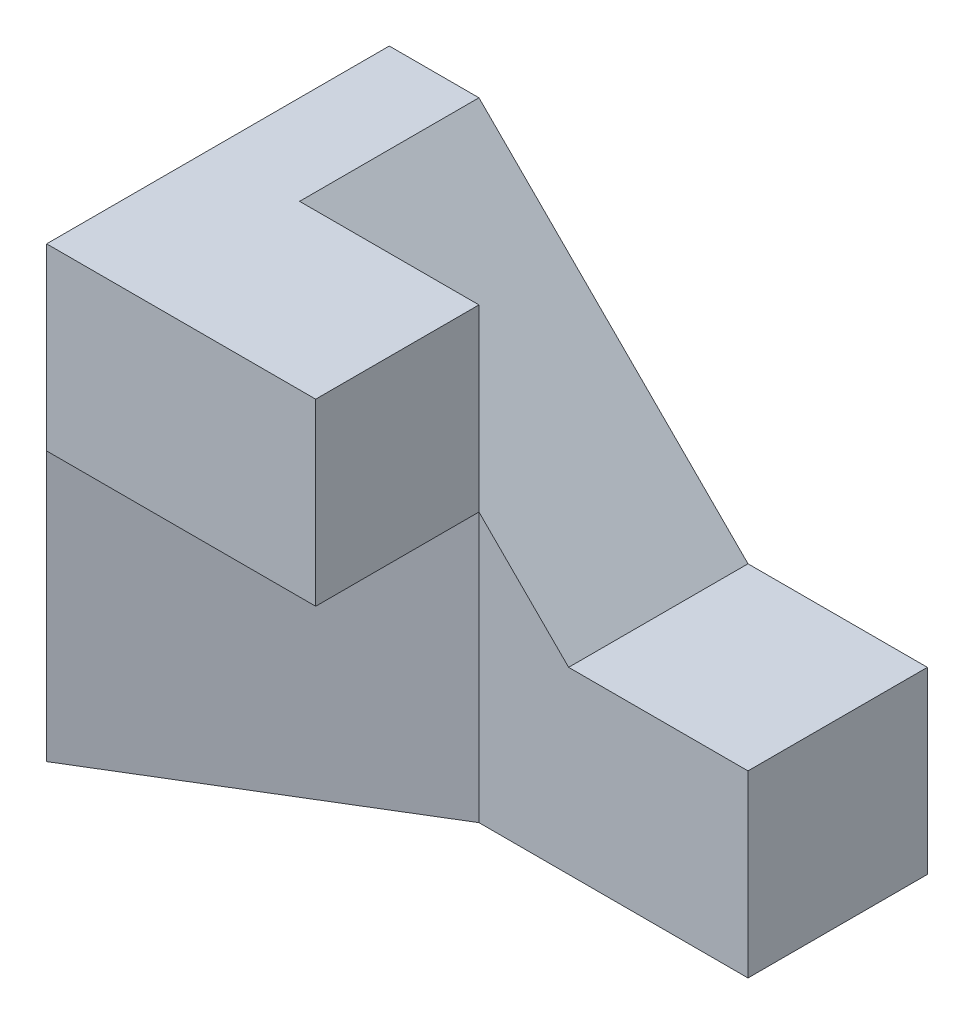
from build123d import *

# Parameters (mm, degrees)
BOSS_EXTRUDE1_DEPTH = 2
SKETCH2_W           = 1.82062343
SKETCH2_H           = 2
BOSS_EXTRUDE2_DEPTH = 3
BOSS_EXTRUDE3_DEPTH = 3


with BuildPart() as part:
    # Sketch1 → Boss-Extrude1 (new body)
    with BuildSketch(Plane.XY):
        Polygon((0, 0), (6, 0), (6, 2), (4, 2), (1, 5), (0, 5), align=None)
    extrude(amount=-BOSS_EXTRUDE1_DEPTH)



with BuildPart() as body_2:
    # Sketch2 → Boss-Extrude2 (new body)
    with BuildSketch(Plane.ZY):
        with Locations((0.910311715, 4)):
            Rectangle(SKETCH2_W, SKETCH2_H)
    extrude(amount=-BOSS_EXTRUDE2_DEPTH)


with BuildPart() as part_1:
    add(part.part)

    add(body_2.part)  # Boss-Extrude3 merges body 2
    # Sketch3 → Boss-Extrude3 (add)
    with BuildSketch(Plane.XZ.offset(-3)):
        Polygon((0, 0), (3, 0), (0, 1.82062343), align=None)
    extrude(amount=BOSS_EXTRUDE3_DEPTH)


solid = part_1.part
